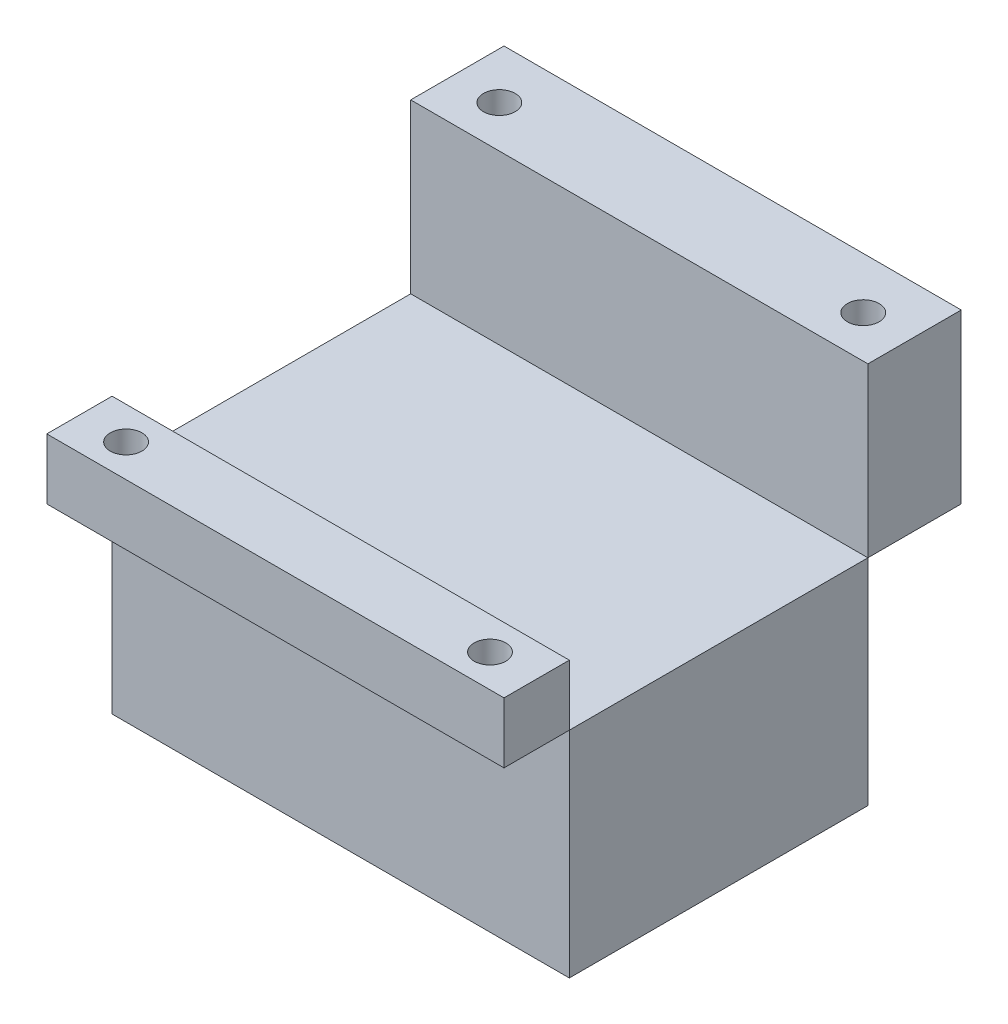
from build123d import *

# Parameters (mm, degrees)
SKETCH_1_W          = 49
SKETCH_1_H          = 32
EXTRUDE_1_DEPTH     = 23
SKETCH_7_W          = 49
SKETCH_7_H          = 7
EXTRUDE_4_DEPTH     = 6.5
SKETCH_8_W          = 49
SKETCH_8_H          = 10
EXTRUDE_5_DEPTH     = 18
SKETCH_10_R         = 1.7
CUT_EXTRUDE_1_DEPTH = 19
SKETCH_11_R         = 1.7
CUT_EXTRUDE_2_DEPTH = 19


with BuildPart() as part:
    # 草圖1 → 填料-伸長1 (new body)
    with BuildSketch(Plane(origin=(0, 0, 0), x_dir=(1, 0, 0), z_dir=(0, 1, 0))):
        Rectangle(SKETCH_1_W, SKETCH_1_H)
    extrude(amount=EXTRUDE_1_DEPTH)


with BuildPart() as body_2:
    # 草圖7 → 填料-伸長4 (new body)
    with BuildSketch(Plane(origin=(0, 23, 0), x_dir=(1, 0, 0), z_dir=(0, 1, 0))):
        with Locations((0, -19.5)):
            Rectangle(SKETCH_7_W, SKETCH_7_H)
    extrude(amount=EXTRUDE_4_DEPTH)

    # 草圖11 → 除料-伸長2 (cut, through all)
    with BuildSketch(Plane.XZ.offset(-23)):
        with Locations((19.5, 19.5)):
            Circle(SKETCH_11_R)
        with Locations((-19.5, 19.5)):
            Circle(SKETCH_11_R)
    extrude(amount=-CUT_EXTRUDE_2_DEPTH, mode=Mode.SUBTRACT)


with BuildPart() as body_3:
    # 草圖8 → 填料-伸長5 (new body)
    with BuildSketch(Plane(origin=(0, 23, 0), x_dir=(1, 0, 0), z_dir=(0, 1, 0))):
        with Locations((0, 21)):
            Rectangle(SKETCH_8_W, SKETCH_8_H)
    extrude(amount=EXTRUDE_5_DEPTH)

    # 草圖10 → 除料-伸長1 (cut, through all)
    with BuildSketch(Plane.XZ.offset(-23)):
        with Locations((-19.5, -20.5)):
            Circle(SKETCH_10_R)
        with Locations((19.5, -20.5)):
            Circle(SKETCH_10_R)
    extrude(amount=-CUT_EXTRUDE_1_DEPTH, mode=Mode.SUBTRACT)


solid = Compound([part.part, body_2.part, body_3.part])
